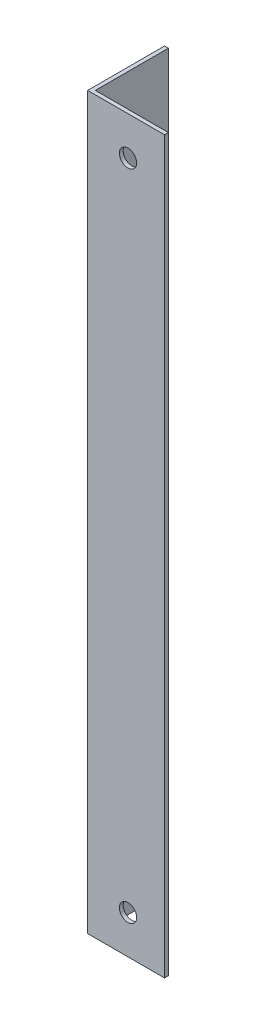
from build123d import *

# Parameters (mm, degrees)
EXTRUDE_1_DEPTH     = 190
SKETCH_2_R          = 2.25
CUT_EXTRUDE_1_DEPTH = 2
SKETCH1_R           = 1.6
CUT_EXTRUDE1_DEPTH  = 2


with BuildPart() as part:
    # Эскиз1 → Бобышка-Вытянуть1 (new body)
    with BuildSketch(Plane(origin=(0, 0, 0), x_dir=(1, 0, 0), z_dir=(0, 1, 0))):
        Polygon((0, 0), (0, 20), (1, 20), (1, 1), (20, 1), (20, 0), align=None)
    extrude(amount=EXTRUDE_1_DEPTH)

    # Эскиз2 → Вырез-Вытянуть1 (cut, through all)
    with BuildSketch(Plane(origin=(0, 0, -1), x_dir=(-1, 0, 0), z_dir=(0, 0, -1))):
        with Locations((-10.5, 10)):
            Circle(SKETCH_2_R)
        with Locations((-10.5, 180)):
            Circle(SKETCH_2_R)
    extrude(amount=-CUT_EXTRUDE_1_DEPTH, mode=Mode.SUBTRACT)

    # Sketch1 → Cut-Extrude1 (cut, through all)
    with BuildSketch(Plane(origin=(1, 0, 0), x_dir=(0, 0, -1), z_dir=(1, 0, 0))):
        with Locations((7, 155)):
            Circle(SKETCH1_R)
        with Locations((7, 122)):
            Circle(SKETCH1_R)
    extrude(amount=-CUT_EXTRUDE1_DEPTH, mode=Mode.SUBTRACT)


solid = part.part
